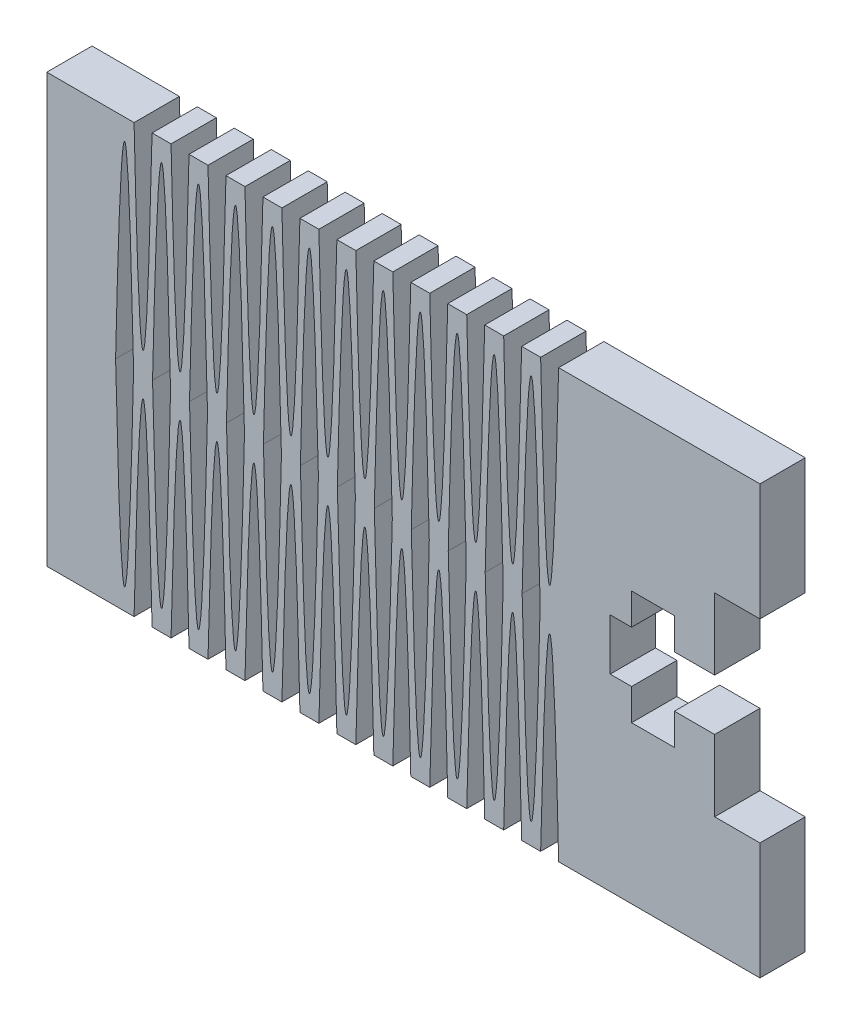
from build123d import *

# Parameters (mm, degrees)
BOSS_EXTRUDE1_DEPTH = 3.175


with BuildPart() as part:
    # Sketch1 → Boss-Extrude1 (new body)
    with BuildSketch(Plane.XY):
        with BuildLine():
            Line((-46.911258203, 77.257267205), (-46.911258203, 85.457267205))
            Line((-46.911258203, 85.457267205), (-61.025093708, 85.457267205))
            add(Edge.make_bspline(
                [(-61.025093708, 85.457267205), (-61.655906271, 58.402357683), (-62.286718834, 85.457267205)],
                knots=[0, 0, 0, 1, 1, 1], degree=2))
            Line((-62.286718834, 85.457267205), (-63.616268409, 85.457267205))
            add(Edge.make_bspline(
                [(-64.877893535, 85.457267205), (-64.247080972, 58.402357683), (-63.616268409, 85.457267205)],
                knots=[0, 0, 0, 1, 1, 1], degree=2))
            Line((-64.877893535, 85.457267205), (-66.207510978, 85.457267205))
            add(Edge.make_bspline(
                [(-66.207510978, 85.457267205), (-66.838212082, 58.40223111), (-67.469136108, 85.457496903)],
                knots=[0, 0, 0, 1, 1, 1], degree=2))
            Line((-67.469136108, 85.457496903), (-68.798685682, 85.457482171))
            add(Edge.make_bspline(
                [(-70.060310806, 85.457246765), (-69.429365141, 58.402225249), (-68.798685682, 85.457482171)],
                knots=[0, 0, 0, 1, 1, 1], degree=2))
            Line((-70.060310806, 85.457246765), (-71.390030732, 85.457246765))
            add(Edge.make_bspline(
                [(-71.390030732, 85.457246765), (-72.020965708, 58.402340098), (-72.651655859, 85.457252473)],
                knots=[0, 0, 0, 1, 1, 1], degree=2))
            Line((-72.651655859, 85.457252473), (-73.981205433, 85.457267205))
            add(Edge.make_bspline(
                [(-75.24283056, 85.457267205), (-74.612140143, 58.402345959), (-73.981205433, 85.457267205)],
                knots=[0, 0, 0, 1, 1, 1], degree=2))
            Line((-75.24283056, 85.457267205), (-76.572448003, 85.457267205))
            add(Edge.make_bspline(
                [(-76.572448003, 85.457267205), (-77.203260566, 58.402357683), (-77.83407313, 85.457267205)],
                knots=[0, 0, 0, 1, 1, 1], degree=2))
            Line((-77.83407313, 85.457267205), (-79.163622704, 85.457267205))
            add(Edge.make_bspline(
                [(-80.425247831, 85.457267205), (-79.794435267, 58.402357683), (-79.163622704, 85.457267205)],
                knots=[0, 0, 0, 1, 1, 1], degree=2))
            Line((-80.425247831, 85.457267205), (-81.755225929, 85.457267205))
            add(Edge.make_bspline(
                [(-81.755225929, 85.457267205), (-82.386038492, 58.402357683), (-83.016851056, 85.457267205)],
                knots=[0, 0, 0, 1, 1, 1], degree=2))
            Line((-83.016851056, 85.457267205), (-84.34640063, 85.457267205))
            add(Edge.make_bspline(
                [(-85.608025757, 85.457267205), (-84.977213193, 58.402357683), (-84.34640063, 85.457267205)],
                knots=[0, 0, 0, 1, 1, 1], degree=2))
            Line((-85.608025757, 85.457267205), (-86.9376432, 85.457267205))
            add(Edge.make_bspline(
                [(-86.9376432, 85.457267205), (-87.568333617, 58.402345959), (-88.199268326, 85.457267205)],
                knots=[0, 0, 0, 1, 1, 1], degree=2))
            Line((-88.199268326, 85.457267205), (-89.528817901, 85.457252473))
            add(Edge.make_bspline(
                [(-90.790443027, 85.457246765), (-90.159508052, 58.402340098), (-89.528817901, 85.457252473)],
                knots=[0, 0, 0, 1, 1, 1], degree=2))
            Line((-90.790443027, 85.457246765), (-96.911258203, 85.457267205))
            Line((-96.911258203, 85.457267205), (-96.911258203, 55.457267205))
            Line((-96.911258203, 55.457267205), (-90.79030729, 55.457246765))
            add(Edge.make_bspline(
                [(-90.79030729, 55.457246765), (-90.159617139, 82.512159141), (-89.528682163, 55.457252473)],
                knots=[0, 0, 0, 1, 1, 1], degree=2))
            Line((-89.528682163, 55.457252473), (-88.199132589, 55.457267205))
            add(Edge.make_bspline(
                [(-86.937507462, 55.457267205), (-87.568442172, 82.512165003), (-88.199132589, 55.457267205)],
                knots=[0, 0, 0, 1, 1, 1], degree=2))
            Line((-86.937507462, 55.457267205), (-85.608025757, 55.457267205))
            add(Edge.make_bspline(
                [(-85.608025757, 55.457267205), (-84.977213193, 82.512176727), (-84.34640063, 55.457267205)],
                knots=[0, 0, 0, 1, 1, 1], degree=2))
            Line((-84.34640063, 55.457267205), (-83.016851056, 55.457267205))
            add(Edge.make_bspline(
                [(-81.755225929, 55.457267205), (-82.386038492, 82.512176727), (-83.016851056, 55.457267205)],
                knots=[0, 0, 0, 1, 1, 1], degree=2))
            Line((-81.755225929, 55.457267205), (-80.425247831, 55.457267205))
            add(Edge.make_bspline(
                [(-80.425247831, 55.457267205), (-79.794435267, 82.512176727), (-79.163622704, 55.457267205)],
                knots=[0, 0, 0, 1, 1, 1], degree=2))
            Line((-79.163622704, 55.457267205), (-77.83407313, 55.457267205))
            add(Edge.make_bspline(
                [(-76.572448003, 55.457267205), (-77.203260566, 82.512176727), (-77.83407313, 55.457267205)],
                knots=[0, 0, 0, 1, 1, 1], degree=2))
            Line((-76.572448003, 55.457267205), (-75.242966297, 55.457267205))
            add(Edge.make_bspline(
                [(-75.242966297, 55.457267205), (-74.612031588, 82.512165003), (-73.981341171, 55.457267205)],
                knots=[0, 0, 0, 1, 1, 1], degree=2))
            Line((-73.981341171, 55.457267205), (-72.651791596, 55.457252473))
            add(Edge.make_bspline(
                [(-71.39016647, 55.457246765), (-72.020856621, 82.512159141), (-72.651791596, 55.457252473)],
                knots=[0, 0, 0, 1, 1, 1], degree=2))
            Line((-71.39016647, 55.457246765), (-70.060175069, 55.457246765))
            add(Edge.make_bspline(
                [(-70.060175069, 55.457246765), (-69.429484917, 82.512159141), (-68.798549942, 55.457252473)],
                knots=[0, 0, 0, 1, 1, 1], degree=2))
            Line((-68.798549942, 55.457252473), (-67.469000368, 55.457267205))
            add(Edge.make_bspline(
                [(-66.207375241, 55.457267205), (-66.838309951, 82.512165003), (-67.469000368, 55.457267205)],
                knots=[0, 0, 0, 1, 1, 1], degree=2))
            Line((-66.207375241, 55.457267205), (-64.877893535, 55.457267205))
            add(Edge.make_bspline(
                [(-64.877893535, 55.457267205), (-64.247080972, 82.512176727), (-63.616268409, 55.457267205)],
                knots=[0, 0, 0, 1, 1, 1], degree=2))
            Line((-63.616268409, 55.457267205), (-62.286718834, 55.457267205))
            add(Edge.make_bspline(
                [(-61.025093708, 55.457267205), (-61.655906271, 82.512176727), (-62.286718834, 55.457267205)],
                knots=[0, 0, 0, 1, 1, 1], degree=2))
            Line((-61.025093708, 55.457267205), (-46.911258203, 55.457267205))
            Line((-46.911258203, 55.457267205), (-46.911258203, 63.657267205))
            Line((-46.911258203, 63.657267205), (-50.086258203, 63.657267205))
            Line((-50.086258203, 63.657267205), (-50.086258203, 68.657267205))
            Line((-50.086258203, 68.657267205), (-52.911258203, 68.657267205))
            Line((-52.911258203, 68.657267205), (-52.911258203, 66.457267205))
            Line((-52.911258203, 66.457267205), (-55.911258203, 66.457267205))
            Line((-55.911258203, 66.457267205), (-55.911258203, 68.657267205))
            Line((-55.911258203, 68.657267205), (-57.411258203, 68.657267205))
            Line((-57.411258203, 68.657267205), (-57.411258203, 72.257267205))
            Line((-57.411258203, 72.257267205), (-55.911258203, 72.257267205))
            Line((-55.911258203, 72.257267205), (-55.911258203, 74.457267205))
            Line((-55.911258203, 74.457267205), (-52.911258203, 74.457267205))
            Line((-52.911258203, 74.457267205), (-52.911258203, 72.257267205))
            Line((-52.911258203, 72.257267205), (-50.086258203, 72.257267205))
            Line((-50.086258203, 72.257267205), (-50.086258203, 77.257267205))
            Line((-50.086258203, 77.257267205), (-46.911258203, 77.257267205))
        make_face()
        with BuildLine():
            Line((-63.582306185, 70.459898744), (-63.582306185, 70.454635666))
            add(Edge.make_bspline(
                [(-62.320681058, 70.457267205), (-62.951371186, 43.398410376), (-63.582306185, 70.454635666)],
                knots=[0, 0, 0, 1, 1, 1], degree=2))
            add(Edge.make_bspline(
                [(-62.320681058, 70.457267205), (-62.951371186, 97.516124034), (-63.582306185, 70.459898744)],
                knots=[0, 0, 0, 1, 1, 1], degree=2))
        make_face(mode=Mode.SUBTRACT)
        with BuildLine():
            Line((-64.911855759, 70.459898744), (-64.911855759, 70.454635666))
            add(Edge.make_bspline(
                [(-66.173480886, 70.457267205), (-65.542790758, 43.398410376), (-64.911855759, 70.454635666)],
                knots=[0, 0, 0, 1, 1, 1], degree=2))
            add(Edge.make_bspline(
                [(-66.173480886, 70.457267205), (-65.542790758, 97.516124034), (-64.911855759, 70.459898744)],
                knots=[0, 0, 0, 1, 1, 1], degree=2))
        make_face(mode=Mode.SUBTRACT)
        with BuildLine():
            Line((-68.764655563, 70.454618234), (-68.764655611, 70.459881312))
            add(Edge.make_bspline(
                [(-67.50303046, 70.457261189), (-68.133965447, 97.51611231), (-68.764655611, 70.459881312)],
                knots=[0, 0, 0, 1, 1, 1], degree=2))
            add(Edge.make_bspline(
                [(-67.50303046, 70.457261189), (-68.133475728, 43.398398654), (-68.764655563, 70.454618234)],
                knots=[0, 0, 0, 1, 1, 1], degree=2))
        make_face(mode=Mode.SUBTRACT)
        with BuildLine():
            Line((-70.094205137, 70.454606203), (-70.094205185, 70.45986928))
            add(Edge.make_bspline(
                [(-71.355830288, 70.457226325), (-70.72538502, 97.51608886), (-70.094205185, 70.45986928)],
                knots=[0, 0, 0, 1, 1, 1], degree=2))
            add(Edge.make_bspline(
                [(-71.355830288, 70.457226325), (-70.7248953, 43.398375204), (-70.094205137, 70.454606203)],
                knots=[0, 0, 0, 1, 1, 1], degree=2))
        make_face(mode=Mode.SUBTRACT)
        with BuildLine():
            Line((-73.947617215, 70.454623638), (-73.94761712, 70.459886715))
            add(Edge.make_bspline(
                [(-72.685992041, 70.457232343), (-73.316192449, 97.516100582), (-73.94761712, 70.459886715)],
                knots=[0, 0, 0, 1, 1, 1], degree=2))
            add(Edge.make_bspline(
                [(-72.685992041, 70.457232343), (-73.317171888, 43.398386933), (-73.947617215, 70.454623638)],
                knots=[0, 0, 0, 1, 1, 1], degree=2))
        make_face(mode=Mode.SUBTRACT)
        with BuildLine():
            Line((-75.27716679, 70.454647701), (-75.277166694, 70.459910778))
            add(Edge.make_bspline(
                [(-76.538791868, 70.457302072), (-75.907612021, 97.516147483), (-75.277166694, 70.459910778)],
                knots=[0, 0, 0, 1, 1, 1], degree=2))
            add(Edge.make_bspline(
                [(-76.538791868, 70.457302072), (-75.908591461, 43.398433833), (-75.27716679, 70.454647701)],
                knots=[0, 0, 0, 1, 1, 1], degree=2))
        make_face(mode=Mode.SUBTRACT)
        with BuildLine():
            Line((-79.129966593, 70.454699997), (-79.129966545, 70.459963075))
            add(Edge.make_bspline(
                [(-77.868341443, 70.457320119), (-78.49878671, 97.516182655), (-79.129966545, 70.459963075)],
                knots=[0, 0, 0, 1, 1, 1], degree=2))
            add(Edge.make_bspline(
                [(-77.868341443, 70.457320119), (-78.49927643, 43.398468999), (-79.129966593, 70.454699997)],
                knots=[0, 0, 0, 1, 1, 1], degree=2))
        make_face(mode=Mode.SUBTRACT)
        with BuildLine():
            Line((-80.459516167, 70.454712029), (-80.45951612, 70.459975106))
            add(Edge.make_bspline(
                [(-81.72114127, 70.457354984), (-81.090206283, 97.516206105), (-80.45951612, 70.459975106)],
                knots=[0, 0, 0, 1, 1, 1], degree=2))
            add(Edge.make_bspline(
                [(-81.72114127, 70.457354984), (-81.090696002, 43.398492449), (-80.459516167, 70.454712029)],
                knots=[0, 0, 0, 1, 1, 1], degree=2))
        make_face(mode=Mode.SUBTRACT)
        with BuildLine():
            Line((-84.312560817, 70.454712029), (-84.312560865, 70.459975106))
            add(Edge.make_bspline(
                [(-83.050935715, 70.457354984), (-83.681870702, 97.516206105), (-84.312560865, 70.459975106)],
                knots=[0, 0, 0, 1, 1, 1], degree=2))
            add(Edge.make_bspline(
                [(-83.050935715, 70.457354984), (-83.681380982, 43.398492449), (-84.312560817, 70.454712029)],
                knots=[0, 0, 0, 1, 1, 1], degree=2))
        make_face(mode=Mode.SUBTRACT)
        with BuildLine():
            Line((-85.642110392, 70.454699997), (-85.642110439, 70.459963075))
            add(Edge.make_bspline(
                [(-86.903735542, 70.457320119), (-86.273290274, 97.516182655), (-85.642110439, 70.459963075)],
                knots=[0, 0, 0, 1, 1, 1], degree=2))
            add(Edge.make_bspline(
                [(-86.903735542, 70.457320119), (-86.272800555, 43.398468999), (-85.642110392, 70.454699997)],
                knots=[0, 0, 0, 1, 1, 1], degree=2))
        make_face(mode=Mode.SUBTRACT)
        with BuildLine():
            Line((-89.494910195, 70.454647701), (-89.49491029, 70.459910778))
            add(Edge.make_bspline(
                [(-88.233285116, 70.457302072), (-88.864464963, 97.516147483), (-89.49491029, 70.459910778)],
                knots=[0, 0, 0, 1, 1, 1], degree=2))
            add(Edge.make_bspline(
                [(-88.233285116, 70.457302072), (-88.863485524, 43.398433833), (-89.494910195, 70.454647701)],
                knots=[0, 0, 0, 1, 1, 1], degree=2))
        make_face(mode=Mode.SUBTRACT)
        with BuildLine():
            Line((-90.824459769, 70.454623638), (-90.824459865, 70.459886715))
            add(Edge.make_bspline(
                [(-92.086084943, 70.457232343), (-91.455884536, 97.516100582), (-90.824459865, 70.459886715)],
                knots=[0, 0, 0, 1, 1, 1], degree=2))
            add(Edge.make_bspline(
                [(-92.086084943, 70.457232343), (-91.454905096, 43.398386933), (-90.824459769, 70.454623638)],
                knots=[0, 0, 0, 1, 1, 1], degree=2))
        make_face(mode=Mode.SUBTRACT)
    extrude(amount=BOSS_EXTRUDE1_DEPTH)


solid = part.part
